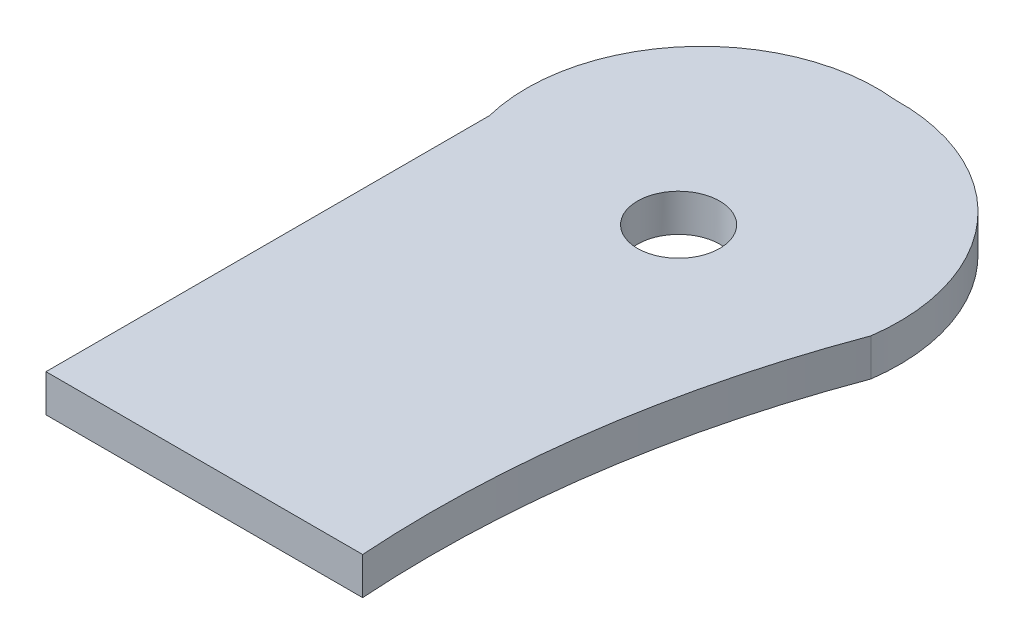
from build123d import *

# Parameters (mm, degrees)
SKETCH1_R           = 7.9375
BOSS_EXTRUDE1_DEPTH = 11.1125
SKETCH2_R           = 12.20390625
CUT_EXTRUDE1_DEPTH  = 11.1125


with BuildPart() as part:
    # Sketch1 → Boss-Extrude1 (new body)
    with BuildSketch(Plane(origin=(0, 0, 0), x_dir=(1, 0, 0), z_dir=(0, 1, 0))):
        with BuildLine():
            Line((-56.1578125, 0), (-56.1578125, -131.7625))
            Line((-56.1578125, -131.7625), (37.9015625, -131.7625))
            ThreePointArc((37.9015625, -131.7625), (40.48606485, -64.852857695), (57.15, 0))
            ThreePointArc((57.15, 0), (43.44844613, 45.367716005), (0, 64.29375))
            ThreePointArc((0, 64.29375), (-44.848953518, 46.794786657), (-56.1578125, 0))
        make_face()
        Circle(SKETCH1_R, mode=Mode.SUBTRACT)
    extrude(amount=BOSS_EXTRUDE1_DEPTH)

    # Sketch2 → Cut-Extrude1 (cut)
    with BuildSketch(Plane(origin=(0, 11.1125, 0), x_dir=(1, 0, 0), z_dir=(0, 1, 0))):
        Circle(SKETCH2_R)
    extrude(amount=-CUT_EXTRUDE1_DEPTH, mode=Mode.SUBTRACT)


solid = part.part
